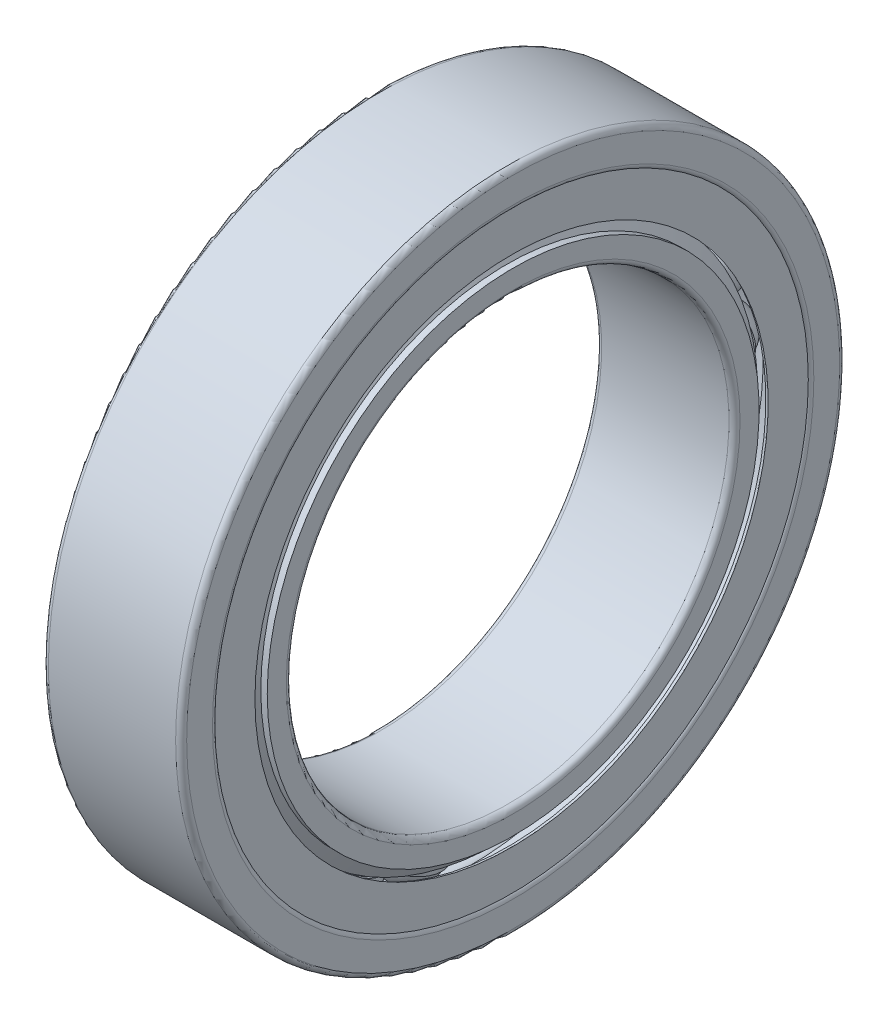
from build123d import *

# Parameters (mm, degrees)
SKETCH_5_W               = 0.3
SKETCH_5_H               = 0.2
PATTERN_CIRCULAR_5_COUNT = 25
PATTERN_CIRCULAR_2_COUNT = 25


with BuildPart() as part:
    # Sketch 2 → Revolve 1 (revolve)
    with BuildSketch(Plane.XY):
        with BuildLine():
            Line((1.005556, 4.666667), (1.133856, 4.444444))
            Line((1.133856, 4.444444), (1.25, 4.444444))
            Line((1.25, 4.444444), (1.25, 4.1))
            ThreePointArc((1.25, 4.1), (1.220711, 4.029289), (1.15, 4))
            Line((1.15, 4), (-1.15, 4))
            ThreePointArc((-1.15, 4), (-1.220711, 4.029289), (-1.25, 4.1))
            Line((-1.25, 4.1), (-1.25, 4.444444))
            Line((-1.25, 4.444444), (-1.133856, 4.444444))
            Line((-1.133856, 4.444444), (-1.005556, 4.666667))
            Line((-1.005556, 4.666667), (-0.372678, 4.666667))
            ThreePointArc((-0.372678, 4.666667), (0, 4.5), (0.372678, 4.666667))
            Line((0.372678, 4.666667), (1.005556, 4.666667))
        make_face()
        with BuildLine():
            Line((-1.25, 5.9), (-1.25, 5.433333))
            ThreePointArc((-1.25, 5.433333), (-1.220711, 5.362623), (-1.15, 5.333333))
            Line((-1.15, 5.333333), (-0.372678, 5.333333))
            ThreePointArc((-0.372678, 5.333333), (0, 5.5), (0.372678, 5.333333))
            Line((0.372678, 5.333333), (1.15, 5.333333))
            ThreePointArc((1.15, 5.333333), (1.220711, 5.362623), (1.25, 5.433333))
            Line((1.25, 5.433333), (1.25, 5.9))
            ThreePointArc((1.25, 5.9), (1.220711, 5.970711), (1.15, 6))
            Line((1.15, 6), (-1.15, 6))
            ThreePointArc((-1.15, 6), (-1.220711, 5.970711), (-1.25, 5.9))
        make_face()
    revolve(axis=Axis((-3.5, 0, 0), (1, 0, 0)))


with BuildPart() as body_2:
    # Sketch 5 → Revolve 3 (revolve)
    with BuildSketch(Plane.XY):
        with Locations((0, 5)):
            Rectangle(SKETCH_5_W, SKETCH_5_H)
    revolve(axis=Axis((-19.927092, 0, 0), (1, 0, 0)))



with BuildPart() as body_3:
    # Sketch 3 → Revolve 2 (revolve)
    with BuildSketch(Plane.XY):
        with BuildLine():
            Line((-0.55, 5), (0.55, 5))
            ThreePointArc((0.55, 5), (0, 5.55), (-0.55, 5))
        make_face()
    revolve(axis=Axis((-0.55, 5, 0), (1, 0, 0)))


with BuildPart() as pattern_circular_5_1:
    # Pattern Circular 5: pattern copy
    add(body_3.part.rotate(Axis((0, 0, 0), (1, 0, 0)), 1 * 360 / PATTERN_CIRCULAR_5_COUNT))


with BuildPart() as pattern_circular_5_2:
    # Pattern Circular 5: pattern copy
    add(body_3.part.rotate(Axis((0, 0, 0), (1, 0, 0)), 2 * 360 / PATTERN_CIRCULAR_5_COUNT))


with BuildPart() as pattern_circular_5_3:
    # Pattern Circular 5: pattern copy
    add(body_3.part.rotate(Axis((0, 0, 0), (1, 0, 0)), 3 * 360 / PATTERN_CIRCULAR_5_COUNT))


with BuildPart() as pattern_circular_5_4:
    # Pattern Circular 5: pattern copy
    add(body_3.part.rotate(Axis((0, 0, 0), (1, 0, 0)), 4 * 360 / PATTERN_CIRCULAR_5_COUNT))


with BuildPart() as pattern_circular_5_5:
    # Pattern Circular 5: pattern copy
    add(body_3.part.rotate(Axis((0, 0, 0), (1, 0, 0)), 5 * 360 / PATTERN_CIRCULAR_5_COUNT))


with BuildPart() as pattern_circular_5_6:
    # Pattern Circular 5: pattern copy
    add(body_3.part.rotate(Axis((0, 0, 0), (1, 0, 0)), 6 * 360 / PATTERN_CIRCULAR_5_COUNT))


with BuildPart() as pattern_circular_5_7:
    # Pattern Circular 5: pattern copy
    add(body_3.part.rotate(Axis((0, 0, 0), (1, 0, 0)), 7 * 360 / PATTERN_CIRCULAR_5_COUNT))


with BuildPart() as pattern_circular_5_8:
    # Pattern Circular 5: pattern copy
    add(body_3.part.rotate(Axis((0, 0, 0), (1, 0, 0)), 8 * 360 / PATTERN_CIRCULAR_5_COUNT))


with BuildPart() as pattern_circular_5_9:
    # Pattern Circular 5: pattern copy
    add(body_3.part.rotate(Axis((0, 0, 0), (1, 0, 0)), 9 * 360 / PATTERN_CIRCULAR_5_COUNT))


with BuildPart() as pattern_circular_5_10:
    # Pattern Circular 5: pattern copy
    add(body_3.part.rotate(Axis((0, 0, 0), (1, 0, 0)), 10 * 360 / PATTERN_CIRCULAR_5_COUNT))


with BuildPart() as pattern_circular_5_11:
    # Pattern Circular 5: pattern copy
    add(body_3.part.rotate(Axis((0, 0, 0), (1, 0, 0)), 11 * 360 / PATTERN_CIRCULAR_5_COUNT))


with BuildPart() as pattern_circular_5_12:
    # Pattern Circular 5: pattern copy
    add(body_3.part.rotate(Axis((0, 0, 0), (1, 0, 0)), 12 * 360 / PATTERN_CIRCULAR_5_COUNT))


with BuildPart() as pattern_circular_5_13:
    # Pattern Circular 5: pattern copy
    add(body_3.part.rotate(Axis((0, 0, 0), (1, 0, 0)), 13 * 360 / PATTERN_CIRCULAR_5_COUNT))


with BuildPart() as pattern_circular_5_14:
    # Pattern Circular 5: pattern copy
    add(body_3.part.rotate(Axis((0, 0, 0), (1, 0, 0)), 14 * 360 / PATTERN_CIRCULAR_5_COUNT))


with BuildPart() as pattern_circular_5_15:
    # Pattern Circular 5: pattern copy
    add(body_3.part.rotate(Axis((0, 0, 0), (1, 0, 0)), 15 * 360 / PATTERN_CIRCULAR_5_COUNT))


with BuildPart() as pattern_circular_5_16:
    # Pattern Circular 5: pattern copy
    add(body_3.part.rotate(Axis((0, 0, 0), (1, 0, 0)), 16 * 360 / PATTERN_CIRCULAR_5_COUNT))


with BuildPart() as pattern_circular_5_17:
    # Pattern Circular 5: pattern copy
    add(body_3.part.rotate(Axis((0, 0, 0), (1, 0, 0)), 17 * 360 / PATTERN_CIRCULAR_5_COUNT))


with BuildPart() as pattern_circular_5_18:
    # Pattern Circular 5: pattern copy
    add(body_3.part.rotate(Axis((0, 0, 0), (1, 0, 0)), 18 * 360 / PATTERN_CIRCULAR_5_COUNT))


with BuildPart() as pattern_circular_5_19:
    # Pattern Circular 5: pattern copy
    add(body_3.part.rotate(Axis((0, 0, 0), (1, 0, 0)), 19 * 360 / PATTERN_CIRCULAR_5_COUNT))


with BuildPart() as pattern_circular_5_20:
    # Pattern Circular 5: pattern copy
    add(body_3.part.rotate(Axis((0, 0, 0), (1, 0, 0)), 20 * 360 / PATTERN_CIRCULAR_5_COUNT))


with BuildPart() as pattern_circular_5_21:
    # Pattern Circular 5: pattern copy
    add(body_3.part.rotate(Axis((0, 0, 0), (1, 0, 0)), 21 * 360 / PATTERN_CIRCULAR_5_COUNT))


with BuildPart() as pattern_circular_5_22:
    # Pattern Circular 5: pattern copy
    add(body_3.part.rotate(Axis((0, 0, 0), (1, 0, 0)), 22 * 360 / PATTERN_CIRCULAR_5_COUNT))


with BuildPart() as pattern_circular_5_23:
    # Pattern Circular 5: pattern copy
    add(body_3.part.rotate(Axis((0, 0, 0), (1, 0, 0)), 23 * 360 / PATTERN_CIRCULAR_5_COUNT))


with BuildPart() as pattern_circular_5_24:
    # Pattern Circular 5: pattern copy
    add(body_3.part.rotate(Axis((0, 0, 0), (1, 0, 0)), 24 * 360 / PATTERN_CIRCULAR_5_COUNT))


with BuildPart() as cut_revolve_1_tool:
    # Sketch 6 → Cut-Revolve 1 (revolve)
    with BuildSketch(Plane.XY):
        with BuildLine():
            Line((-0.540833, 5.1), (0.540833, 5.1))
            ThreePointArc((0.540833, 5.1), (0, 5.55), (-0.540833, 5.1))
        make_face()
        with BuildLine():
            Line((-0.540833, 4.9), (0.540833, 4.9))
            ThreePointArc((0.540833, 4.9), (0, 4.45), (-0.540833, 4.9))
        make_face()
    revolve(axis=Axis((-19.927092, 0, 0), (1, 0, 0)))


with BuildPart() as part_1:
    add(part.part)

    # Cut-Revolve 1: cut by cut_revolve_1_tool
    add(cut_revolve_1_tool.part, mode=Mode.SUBTRACT)

    # Sketch 9 → Revolve 5 (revolve)
    with BuildSketch(Plane.XY):
        with BuildLine():
            Line((1.15, 5.333333), (1.15, 4.666667))
            ThreePointArc((1.15, 4.666667), (1.188268, 4.659055), (1.220711, 4.637377))
            Line((1.220711, 4.637377), (1.220711, 5.362623))
            ThreePointArc((1.220711, 5.362623), (1.188268, 5.340945), (1.15, 5.333333))
        make_face()
        with BuildLine():
            Line((-1.220711, 5.362623), (-1.220711, 4.637377))
            ThreePointArc((-1.220711, 4.637377), (-1.188268, 4.659055), (-1.15, 4.666667))
            Line((-1.15, 4.666667), (-1.15, 5.333333))
            ThreePointArc((-1.15, 5.333333), (-1.188268, 5.340945), (-1.220711, 5.362623))
        make_face()
    revolve(axis=Axis((-19.927092, 0, 0), (1, 0, 0)))


with BuildPart() as body_3_1:
    add(body_3.part)

    # Cut-Revolve 1: cut by cut_revolve_1_tool
    add(cut_revolve_1_tool.part, mode=Mode.SUBTRACT)


with BuildPart() as pattern_circular_5_1_1:
    add(pattern_circular_5_1.part)

    # Cut-Revolve 1: cut by cut_revolve_1_tool
    add(cut_revolve_1_tool.part, mode=Mode.SUBTRACT)


with BuildPart() as pattern_circular_5_2_1:
    add(pattern_circular_5_2.part)

    # Cut-Revolve 1: cut by cut_revolve_1_tool
    add(cut_revolve_1_tool.part, mode=Mode.SUBTRACT)


with BuildPart() as pattern_circular_5_3_1:
    add(pattern_circular_5_3.part)

    # Cut-Revolve 1: cut by cut_revolve_1_tool
    add(cut_revolve_1_tool.part, mode=Mode.SUBTRACT)


with BuildPart() as pattern_circular_5_4_1:
    add(pattern_circular_5_4.part)

    # Cut-Revolve 1: cut by cut_revolve_1_tool
    add(cut_revolve_1_tool.part, mode=Mode.SUBTRACT)


with BuildPart() as pattern_circular_5_5_1:
    add(pattern_circular_5_5.part)

    # Cut-Revolve 1: cut by cut_revolve_1_tool
    add(cut_revolve_1_tool.part, mode=Mode.SUBTRACT)


with BuildPart() as pattern_circular_5_6_1:
    add(pattern_circular_5_6.part)

    # Cut-Revolve 1: cut by cut_revolve_1_tool
    add(cut_revolve_1_tool.part, mode=Mode.SUBTRACT)


with BuildPart() as pattern_circular_5_7_1:
    add(pattern_circular_5_7.part)

    # Cut-Revolve 1: cut by cut_revolve_1_tool
    add(cut_revolve_1_tool.part, mode=Mode.SUBTRACT)


with BuildPart() as pattern_circular_5_8_1:
    add(pattern_circular_5_8.part)

    # Cut-Revolve 1: cut by cut_revolve_1_tool
    add(cut_revolve_1_tool.part, mode=Mode.SUBTRACT)


with BuildPart() as pattern_circular_5_9_1:
    add(pattern_circular_5_9.part)

    # Cut-Revolve 1: cut by cut_revolve_1_tool
    add(cut_revolve_1_tool.part, mode=Mode.SUBTRACT)


with BuildPart() as pattern_circular_5_10_1:
    add(pattern_circular_5_10.part)

    # Cut-Revolve 1: cut by cut_revolve_1_tool
    add(cut_revolve_1_tool.part, mode=Mode.SUBTRACT)


with BuildPart() as pattern_circular_5_11_1:
    add(pattern_circular_5_11.part)

    # Cut-Revolve 1: cut by cut_revolve_1_tool
    add(cut_revolve_1_tool.part, mode=Mode.SUBTRACT)


with BuildPart() as pattern_circular_5_12_1:
    add(pattern_circular_5_12.part)

    # Cut-Revolve 1: cut by cut_revolve_1_tool
    add(cut_revolve_1_tool.part, mode=Mode.SUBTRACT)


with BuildPart() as pattern_circular_5_13_1:
    add(pattern_circular_5_13.part)

    # Cut-Revolve 1: cut by cut_revolve_1_tool
    add(cut_revolve_1_tool.part, mode=Mode.SUBTRACT)


with BuildPart() as pattern_circular_5_14_1:
    add(pattern_circular_5_14.part)

    # Cut-Revolve 1: cut by cut_revolve_1_tool
    add(cut_revolve_1_tool.part, mode=Mode.SUBTRACT)


with BuildPart() as pattern_circular_5_15_1:
    add(pattern_circular_5_15.part)

    # Cut-Revolve 1: cut by cut_revolve_1_tool
    add(cut_revolve_1_tool.part, mode=Mode.SUBTRACT)


with BuildPart() as pattern_circular_5_16_1:
    add(pattern_circular_5_16.part)

    # Cut-Revolve 1: cut by cut_revolve_1_tool
    add(cut_revolve_1_tool.part, mode=Mode.SUBTRACT)


with BuildPart() as pattern_circular_5_17_1:
    add(pattern_circular_5_17.part)

    # Cut-Revolve 1: cut by cut_revolve_1_tool
    add(cut_revolve_1_tool.part, mode=Mode.SUBTRACT)


with BuildPart() as pattern_circular_5_18_1:
    add(pattern_circular_5_18.part)

    # Cut-Revolve 1: cut by cut_revolve_1_tool
    add(cut_revolve_1_tool.part, mode=Mode.SUBTRACT)


with BuildPart() as pattern_circular_5_19_1:
    add(pattern_circular_5_19.part)

    # Cut-Revolve 1: cut by cut_revolve_1_tool
    add(cut_revolve_1_tool.part, mode=Mode.SUBTRACT)


with BuildPart() as pattern_circular_5_20_1:
    add(pattern_circular_5_20.part)

    # Cut-Revolve 1: cut by cut_revolve_1_tool
    add(cut_revolve_1_tool.part, mode=Mode.SUBTRACT)


with BuildPart() as pattern_circular_5_21_1:
    add(pattern_circular_5_21.part)

    # Cut-Revolve 1: cut by cut_revolve_1_tool
    add(cut_revolve_1_tool.part, mode=Mode.SUBTRACT)


with BuildPart() as pattern_circular_5_22_1:
    add(pattern_circular_5_22.part)

    # Cut-Revolve 1: cut by cut_revolve_1_tool
    add(cut_revolve_1_tool.part, mode=Mode.SUBTRACT)


with BuildPart() as pattern_circular_5_23_1:
    add(pattern_circular_5_23.part)

    # Cut-Revolve 1: cut by cut_revolve_1_tool
    add(cut_revolve_1_tool.part, mode=Mode.SUBTRACT)


with BuildPart() as pattern_circular_5_24_1:
    add(pattern_circular_5_24.part)

    # Cut-Revolve 1: cut by cut_revolve_1_tool
    add(cut_revolve_1_tool.part, mode=Mode.SUBTRACT)


with BuildPart() as body_2_1:
    add(body_2.part)

    add(body_3_1.part)  # Revolve 4 merges body 3
    # Sketch 7 → Revolve 4 (revolve)
    with BuildSketch(Plane.XY):
        with BuildLine():
            Line((-0.5, 5), (0.5, 5))
            ThreePointArc((0.5, 5), (0, 5.5), (-0.5, 5))
        make_face()
    revolve_4 = revolve(axis=Axis((-0.5, 5, 0), (1, 0, 0)))

    # Pattern Circular 2: Revolve 4 ×25 about axis
    pattern_circular_2_axis = Axis((0, 0, 0), (1, 0, 0))
    for i in range(1, PATTERN_CIRCULAR_2_COUNT):
        add(revolve_4.rotate(pattern_circular_2_axis, i * 360 / PATTERN_CIRCULAR_2_COUNT))


solid = Compound([part_1.part, pattern_circular_5_1_1.part, pattern_circular_5_2_1.part, pattern_circular_5_3_1.part, pattern_circular_5_4_1.part, pattern_circular_5_5_1.part, pattern_circular_5_6_1.part, pattern_circular_5_7_1.part, pattern_circular_5_8_1.part, pattern_circular_5_9_1.part, pattern_circular_5_10_1.part, pattern_circular_5_11_1.part, pattern_circular_5_12_1.part, pattern_circular_5_13_1.part, pattern_circular_5_14_1.part, pattern_circular_5_15_1.part, pattern_circular_5_16_1.part, pattern_circular_5_17_1.part, pattern_circular_5_18_1.part, pattern_circular_5_19_1.part, pattern_circular_5_20_1.part, pattern_circular_5_21_1.part, pattern_circular_5_22_1.part, pattern_circular_5_23_1.part, pattern_circular_5_24_1.part, body_2_1.part])
